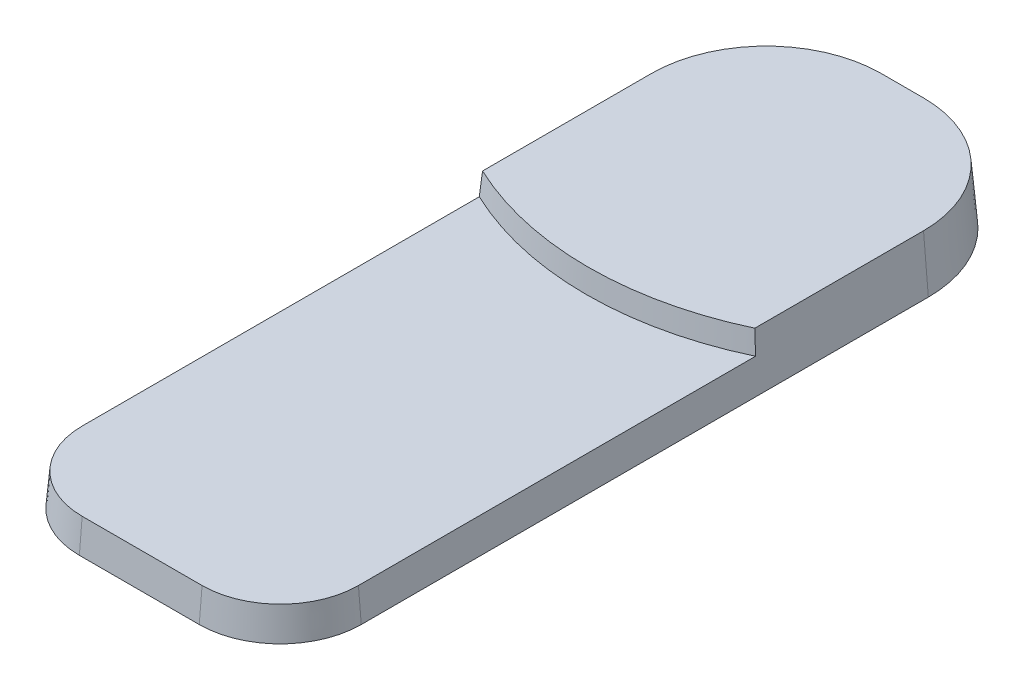
from build123d import *

# Parameters (mm, degrees)
BOSS_EXTRUDE1_DEPTH = 5
BOSS_EXTRUDE1_TAPER = 5
BOSS_EXTRUDE2_DEPTH = 8.5
BOSS_EXTRUDE2_TAPER = 5


with BuildPart() as part:
    # Sketch1 → Boss-Extrude1 (new body)
    with BuildSketch(Plane(origin=(0, 0, 0), x_dir=(1, 0, 0), z_dir=(0, 1, 0))):
        with BuildLine():
            Line((3.25, 59.25), (-3.25, 59.25))
            ThreePointArc((-3.25, 59.25), (-16.331475452, 53.831475452), (-21.75, 40.75))
            Line((-21.75, 40.75), (-21.75, -46.75))
            ThreePointArc((-21.75, -46.75), (-18.088834765, -55.588834765), (-9.25, -59.25))
            Line((-9.25, -59.25), (9.25, -59.25))
            ThreePointArc((9.25, -59.25), (18.088834765, -55.588834765), (21.75, -46.75))
            Line((21.75, -46.75), (21.75, 40.75))
            ThreePointArc((21.75, 40.75), (16.331475452, 53.831475452), (3.25, 59.25))
        make_face()
    extrude(amount=BOSS_EXTRUDE1_DEPTH, taper=BOSS_EXTRUDE1_TAPER)

    # Sketch1_3 → Boss-Extrude2 (add)
    with BuildSketch(Plane(origin=(0, 0, 0), x_dir=(1, 0, 0), z_dir=(0, 1, 0))):
        with BuildLine():
            Line((3.25, 59.25), (-3.25, 59.25))
            ThreePointArc((-3.25, 59.25), (-16.331475452, 53.831475452), (-21.75, 40.75))
            Line((-21.75, 40.75), (-21.75, 14.25))
            ThreePointArc((-21.75, 14.25), (0, 9.271522631), (21.75, 14.25))
            Line((21.75, 14.25), (21.75, 40.75))
            ThreePointArc((21.75, 40.75), (16.331475452, 53.831475452), (3.25, 59.25))
        make_face()
    extrude(amount=BOSS_EXTRUDE2_DEPTH, taper=BOSS_EXTRUDE2_TAPER)


solid = part.part
